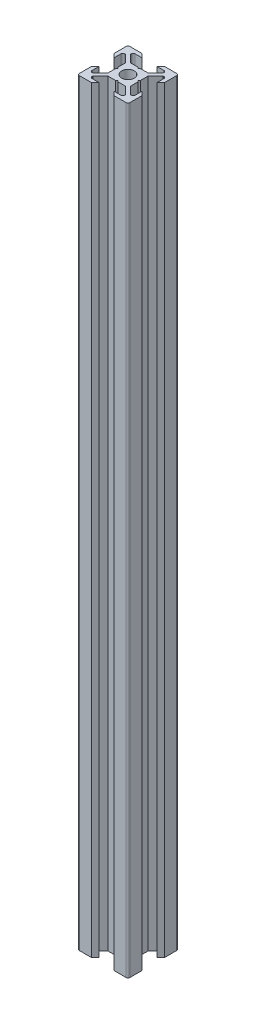
from build123d import *

# Parameters (mm, degrees)
ESQUISSE1_R      = 2.5
EXTRUSION1_DEPTH = 300
CONG_1_R         = 0.75


with BuildPart() as part:
    # Esquisse1 → Extrusion1 (new body)
    with BuildSketch(Plane(origin=(0, 0, 0), x_dir=(1, 0, 0), z_dir=(0, 1, 0))):
        Polygon((0, 4), (-0.5, 4.5), (-3.439339828, 4.5), (-6.439339828, 7.5), (-6.439339828, 8.5), (-3, 8.5), (-4.5, 10), (-10, 10), (-10, 4.5), (-8.5, 3), (-8.5, 6.439339828), (-7.5, 6.439339828), (-4.5, 3.439339828), (-4.5, 0.5), (-4, 0), (-4.5, -0.5), (-4.5, -3.439339828), (-7.5, -6.439339828), (-8.5, -6.439339828), (-8.5, -3), (-10, -4.5), (-10, -10), (-4.5, -10), (-3, -8.5), (-6.439339828, -8.5), (-6.439339828, -7.5), (-3.439339828, -4.5), (-0.5, -4.5), (0, -4), (0.5, -4.5), (3.439339828, -4.5), (6.439339828, -7.5), (6.439339828, -8.5), (3, -8.5), (4.5, -10), (10, -10), (10, -4.5), (8.5, -3), (8.5, -6.439339828), (7.5, -6.439339828), (4.5, -3.439339828), (4.5, -0.5), (4, 0), (4.5, 0.5), (4.5, 3.439339828), (7.5, 6.439339828), (8.5, 6.439339828), (8.5, 3), (10, 4.5), (10, 10), (4.5, 10), (3, 8.5), (6.439339828, 8.5), (6.439339828, 7.5), (3.439339828, 4.5), (0.5, 4.5), align=None)
        Circle(ESQUISSE1_R, mode=Mode.SUBTRACT)
    extrude(amount=EXTRUSION1_DEPTH)

    # Congé1
    cong_1_edges = [part.edges().sort_by_distance(p)[0] for p in [
        (6.439339828, 150, -8.5),
        (10, 150, -10),
        (8.5, 150, -6.439339828),
        (8.5, 150, 6.439339828),
        (10, 150, 10),
        (6.439339828, 150, 8.5),
        (-6.439339828, 150, 8.5),
        (-10, 150, 10),
        (-8.5, 150, 6.439339828),
        (-8.5, 150, -6.439339828),
        (-10, 150, -10),
        (-6.439339828, 150, -8.5),
    ]]
    fillet(cong_1_edges, radius=CONG_1_R)


solid = part.part
